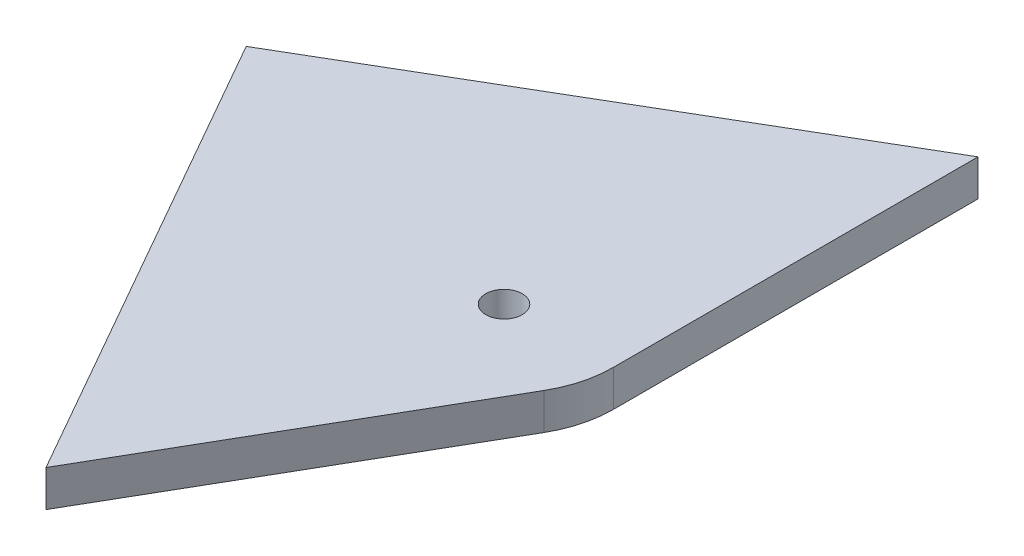
from build123d import *

# Parameters (mm, degrees)
ESQUISSE1_R        = 1
BOSS_EXTRU_1_DEPTH = 2


with BuildPart() as part:
    # Esquisse1 → Boss.-Extru.1 (new body)
    with BuildSketch(Plane(origin=(0, 0, 0), x_dir=(1, 0, 0), z_dir=(0, 1, 0))):
        with BuildLine():
            Line((6, 0), (6, 20))
            Line((6, 20), (-19.318516526, 5.176380902))
            Line((-19.318516526, 5.176380902), (-4.803847577, -20.320508076))
            Line((-4.803847577, -20.320508076), (5.196152423, -3))
            ThreePointArc((5.196152423, -3), (5.795554958, -1.552914271), (6, 0))
        make_face()
        Circle(ESQUISSE1_R, mode=Mode.SUBTRACT)
    extrude(amount=BOSS_EXTRU_1_DEPTH)


solid = part.part
